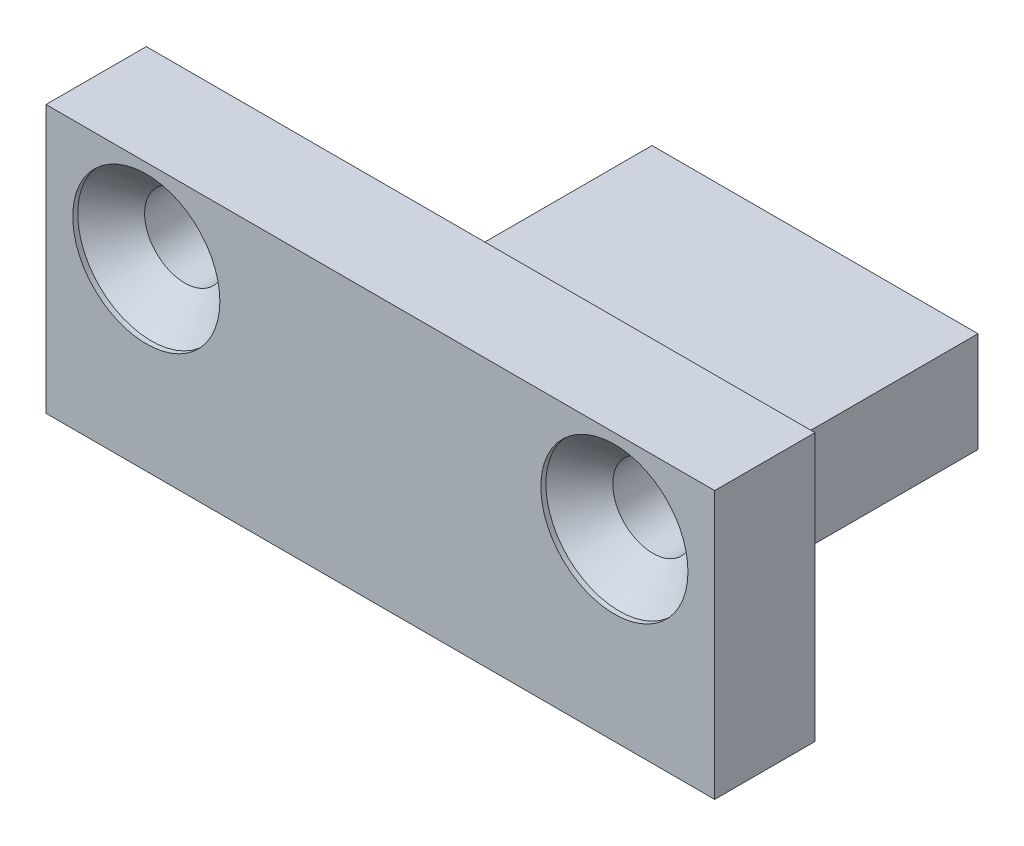
from build123d import *

# Parameters (mm, degrees)
BOSS_EXTRUDE1_DEPTH                            = 10
SKETCH2_W                                      = 5.125
SKETCH2_H                                      = 10
CUT_EXTRUDE1_DEPTH                             = 4
CSK_FOR_M2_FLAT_HEAD_MACHINE_SCREW1_AT_2_COUNT = 2
CSK_FOR_M2_FLAT_HEAD_MACHINE_SCREW1_AT_2_PITCH = 14


with BuildPart() as part:
    # Sketch1 → Boss-Extrude1 (new body, symmetric)
    with BuildSketch(Plane(origin=(0, 0, 0), x_dir=(0, 0, -1), z_dir=(1, 0, 0))):
        Polygon((0, 0), (10, 0), (10, -3), (-3, -3), (-3, 5), (0, 5), align=None)
    extrude(amount=BOSS_EXTRUDE1_DEPTH, both=True)

    # Sketch2 → Cut-Extrude1 (cut, through all)
    with BuildSketch(Plane(origin=(0, 0, 0), x_dir=(1, 0, 0), z_dir=(0, 1, 0))):
        with Locations((-7.4375, 5)):
            Rectangle(SKETCH2_W, SKETCH2_H)
        with Locations((7.4375, 5)):
            Rectangle(SKETCH2_W, SKETCH2_H)
    extrude(amount=-CUT_EXTRUDE1_DEPTH, mode=Mode.SUBTRACT)

    # Sketch4 → CSK for M2 Flat Head Machine Screw1 (revolve, cut)
    with BuildSketch(Plane(origin=(7, 2.5, 3), x_dir=(0, -1, 0), z_dir=(1, 0, 0))):
        Polygon((0, 0), (0, 20.721032743), (1.2, 20), (1.2, 1.15), (2.2, 0.15), (2.2, 0), align=None)
    csk_for_m2_flat_head_machine_screw1 = revolve(axis=Axis((7, 2.5, 9.35), (0, 0, -1)), mode=Mode.SUBTRACT)

    # CSK for M2 Flat Head Machine Screw1 at 2: CSK for M2 Flat Head Machine Screw1 ×2
    with Locations(*[(-i * CSK_FOR_M2_FLAT_HEAD_MACHINE_SCREW1_AT_2_PITCH, 0, 0) for i in range(1, CSK_FOR_M2_FLAT_HEAD_MACHINE_SCREW1_AT_2_COUNT)]):
        add(csk_for_m2_flat_head_machine_screw1, mode=Mode.SUBTRACT)


solid = part.part
